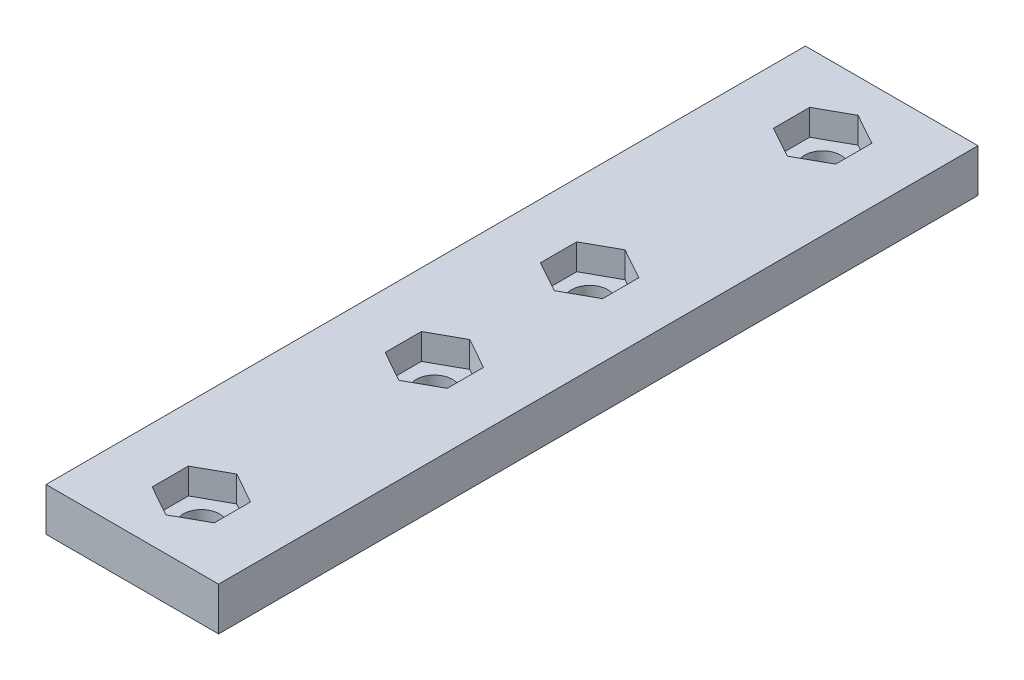
from build123d import *

# Parameters (mm, degrees)
SKETCH1_W           = 20
SKETCH1_H           = 44
SKETCH1_R           = 2.1
BOSS_EXTRUDE1_DEPTH = 5
SKETCH2_R           = 2.1
CUT_EXTRUDE1_DEPTH  = 3


with BuildPart() as part:
    # Sketch1 → Boss-Extrude1 (new body)
    with BuildSketch(Plane(origin=(0, 0, 0), x_dir=(1, 0, 0), z_dir=(0, 1, 0))):
        with Locations((0, -0.5)):
            Rectangle(SKETCH1_W, SKETCH1_H)
        with Locations((0, -13.5)):
            Circle(SKETCH1_R, mode=Mode.SUBTRACT)
        with Locations((0, 13.5)):
            Circle(SKETCH1_R, mode=Mode.SUBTRACT)
        with Locations((0, -44.5)):
            Rectangle(SKETCH1_W, SKETCH1_H)
        with Locations((0, -58.5)):
            Circle(SKETCH1_R, mode=Mode.SUBTRACT)
        with Locations((0, -31.5)):
            Circle(SKETCH1_R, mode=Mode.SUBTRACT)
    extrude(amount=BOSS_EXTRUDE1_DEPTH)

    # Sketch2 → Cut-Extrude1 (cut)
    with BuildSketch(Plane(origin=(0, 5, 0), x_dir=(1, 0, 0), z_dir=(0, 1, 0))):
        Polygon((0, 17.6), (3.6, 15.6), (-3.6, 15.6), align=None)
        with BuildLine():
            ThreePointArc((2.1, 13.5), (1.48492424, 12.01507576), (0, 11.4))
            Line((0, 11.4), (3.6, 11.4))
            Line((3.6, 11.4), (3.6, 15.6))
            Line((3.6, 15.6), (0, 15.6))
            ThreePointArc((0, 15.6), (1.48492424, 14.98492424), (2.1, 13.5))
        make_face()
        with BuildLine():
            Line((-3.6, 15.6), (-3.6, 11.4))
            Line((-3.6, 11.4), (0, 11.4))
            ThreePointArc((0, 11.4), (-2.1, 13.5), (0, 15.6))
            Line((0, 15.6), (-3.6, 15.6))
        make_face()
        Polygon((0, 9.4), (-3.6, 11.4), (3.6, 11.4), align=None)
        Polygon((0, -9.4), (3.6, -11.4), (-3.6, -11.4), align=None)
        with BuildLine():
            ThreePointArc((2.1, -13.5), (1.484924244, -14.984924237), (1e-08, -15.6))
            Line((1e-08, -15.6), (3.6, -15.6))
            Line((3.6, -15.6), (3.6, -11.4))
            Line((3.6, -11.4), (0, -11.4))
            ThreePointArc((0, -11.4), (1.48492424, -12.01507576), (2.1, -13.5))
        make_face()
        with BuildLine():
            Line((-3.6, -11.4), (-3.6, -15.6))
            Line((-3.6, -15.6), (1e-08, -15.6))
            ThreePointArc((1e-08, -15.6), (-2.1, -13.500000005), (0, -11.4))
            Line((0, -11.4), (-3.6, -11.4))
        make_face()
        Polygon((0, -17.6), (-3.6, -15.6), (3.6, -15.6), align=None)
        Polygon((0, -35.6), (-3.6, -33.6), (-3.6, -29.4), (0, -27.4), (3.6, -29.4), (3.6, -33.6), align=None)
        with Locations((0, -31.5)):
            Circle(SKETCH2_R, mode=Mode.SUBTRACT)
        Polygon((0, -62.6), (-3.6, -60.6), (-3.6, -56.4), (0, -54.4), (3.6, -56.4), (3.6, -60.6), align=None)
        with Locations((0, -58.5)):
            Circle(SKETCH2_R, mode=Mode.SUBTRACT)
    extrude(amount=-CUT_EXTRUDE1_DEPTH, mode=Mode.SUBTRACT)


solid = part.part
